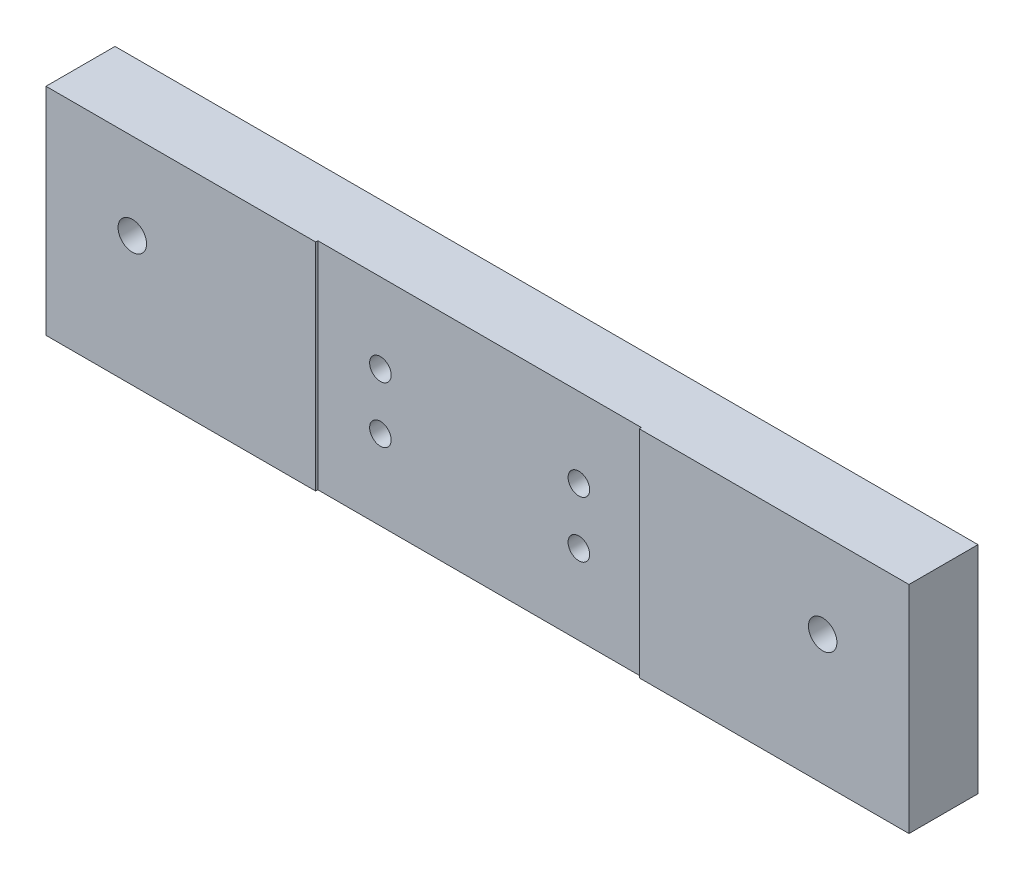
from build123d import *

# Parameters (mm, degrees)
SKETCH1_W                                           = 200
SKETCH1_H                                           = 50
EXTRUDE1_DEPTH                                      = 16
SKETCH2_W                                           = 75
SKETCH2_H                                           = 50
EXTRUDE2_DEPTH                                      = 0.5
M6_TAPPED_HOLE1_D                                   = 5
CBORE_FOR_M6_HEX_SOCKET_HEAD_CAP_SCREW1_D           = 6.6
CBORE_FOR_M6_HEX_SOCKET_HEAD_CAP_SCREW1_CBORE_D     = 11
CBORE_FOR_M6_HEX_SOCKET_HEAD_CAP_SCREW1_CBORE_DEPTH = 6.4


with BuildPart() as part:
    # Sketch1 → Extrude1 (new body)
    with BuildSketch(Plane.XY):
        Rectangle(SKETCH1_W, SKETCH1_H)
    extrude(amount=EXTRUDE1_DEPTH)

    # Sketch2 → Extrude2 (cut)
    with BuildSketch(Plane.XY.offset(16)):
        Rectangle(SKETCH2_W, SKETCH2_H)
    extrude(amount=-EXTRUDE2_DEPTH, mode=Mode.SUBTRACT)

    # M6 Tapped Hole1 (through all)
    with Locations(Plane.XY.offset(15.5)):
        with Locations((-23, 6.5), (-23, -6.5), (23, -6.5), (23, 6.5)):
            Hole(M6_TAPPED_HOLE1_D / 2)

    # CBORE for M6 Hex Socket Head Cap Screw1 (through all)
    with Locations(Plane(origin=(0, 0, 0), x_dir=(-1, 0, 0), z_dir=(0, 0, -1))):
        with Locations((-80, 5), (80, 5)):
            CounterBoreHole(CBORE_FOR_M6_HEX_SOCKET_HEAD_CAP_SCREW1_D / 2, CBORE_FOR_M6_HEX_SOCKET_HEAD_CAP_SCREW1_CBORE_D / 2, CBORE_FOR_M6_HEX_SOCKET_HEAD_CAP_SCREW1_CBORE_DEPTH)


solid = part.part
